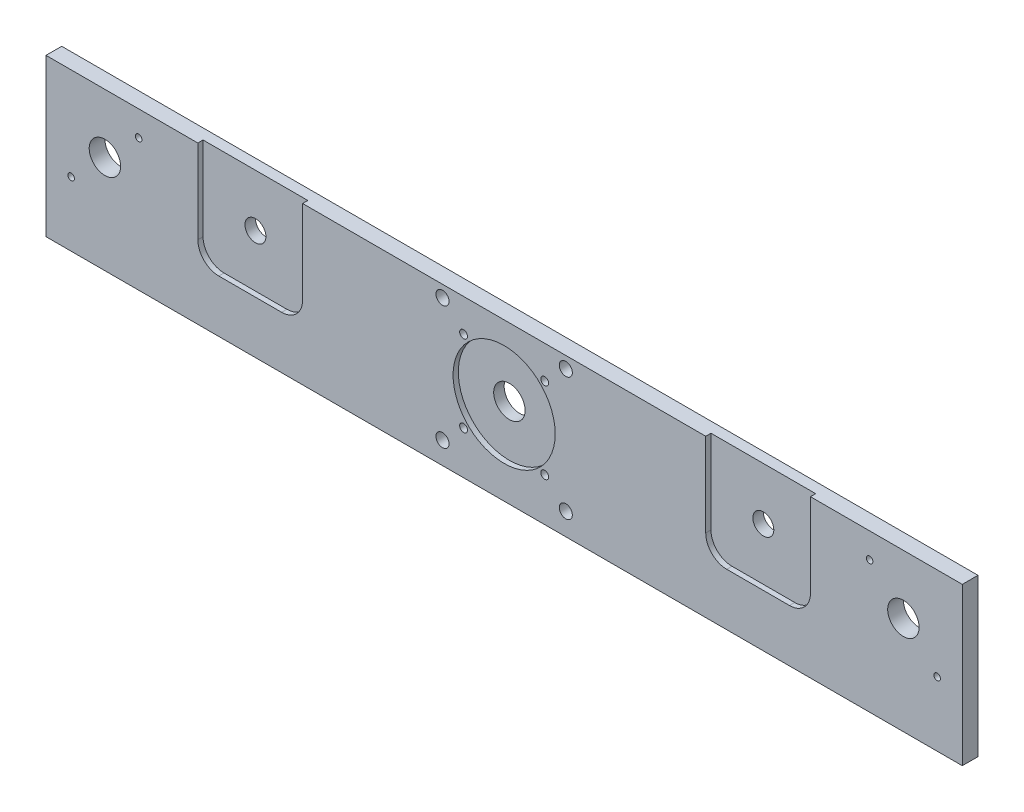
from build123d import *

# Parameters (mm, degrees)
CROQUIS1_W              = 350
CROQUIS1_H              = 60
SALIENTE_EXTRUIR1_DEPTH = 6
CROQUIS2_R              = 6
CROQUIS2_R_2            = 1.25
CORTAR_EXTRUIR1_DEPTH   = 7
CROQUIS3_R              = 6
CROQUIS3_R_2            = 1.5
CROQUIS3_R_3            = 2.5
CORTAR_EXTRUIR2_DEPTH   = 7
CROQUIS5_R              = 19.5
CORTAR_EXTRUIR4_DEPTH   = 2
CROQUIS7_R              = 4
CORTAR_EXTRUIR5_DEPTH   = 5


with BuildPart() as part:
    # Croquis1 → Saliente-Extruir1 (new body)
    with BuildSketch(Plane.XY):
        with Locations((-175, -30)):
            Rectangle(CROQUIS1_W, CROQUIS1_H)
    extrude(amount=SALIENTE_EXTRUIR1_DEPTH)

    # Croquis2 → Cortar-Extruir1 (cut, through all)
    with BuildSketch(Plane.XY.offset(6)):
        with Locations((-327.5, -22.5)):
            Circle(CROQUIS2_R)
        with Locations((-22.5, -22.5)):
            Circle(CROQUIS2_R)
        with Locations((-314.595301243, -9.595301243)):
            Circle(CROQUIS2_R_2)
        with Locations((-340.404698757, -35.404698757)):
            Circle(CROQUIS2_R_2)
        with Locations((-35.404698757, -9.595301243)):
            Circle(CROQUIS2_R_2)
        with Locations((-9.595301243, -35.404698757)):
            Circle(CROQUIS2_R_2)
    extrude(amount=-CORTAR_EXTRUIR1_DEPTH, mode=Mode.SUBTRACT)

    # Croquis3 → Cortar-Extruir2 (cut, through all)
    with BuildSketch(Plane.XY.offset(6)):
        with Locations((-175, -28)):
            Circle(CROQUIS3_R)
        with Locations((-190.5, -12.5)):
            Circle(CROQUIS3_R_2)
        with Locations((-159.5, -12.5)):
            Circle(CROQUIS3_R_2)
        with Locations((-190.5, -43.5)):
            Circle(CROQUIS3_R_2)
        with Locations((-151.45, -51.55)):
            Circle(CROQUIS3_R_3)
        with Locations((-198.55, -51.55)):
            Circle(CROQUIS3_R_3)
        with Locations((-159.5, -43.5)):
            Circle(CROQUIS3_R_2)
        with Locations((-151.45, -4.45)):
            Circle(CROQUIS3_R_3)
        with Locations((-198.55, -4.45)):
            Circle(CROQUIS3_R_3)
    extrude(amount=-CORTAR_EXTRUIR2_DEPTH, mode=Mode.SUBTRACT)

    # Croquis5 → Cortar-Extruir4 (cut)
    with BuildSketch(Plane.XY.offset(6)):
        with Locations((-175, -28)):
            Circle(CROQUIS5_R)
        with BuildLine():
            Line((-292, 0), (-252, 0))
            Line((-252, 0), (-252, -32))
            ThreePointArc((-252, -32), (-254.343145751, -37.656854249), (-260, -40))
            Line((-260, -40), (-284, -40))
            ThreePointArc((-284, -40), (-289.656854249, -37.656854249), (-292, -32))
            Line((-292, -32), (-292, 0))
        make_face()
        with BuildLine():
            Line((-98, 0), (-58, 0))
            Line((-58, 0), (-58, -32))
            ThreePointArc((-58, -32), (-60.343145751, -37.656854249), (-66, -40))
            Line((-66, -40), (-90, -40))
            ThreePointArc((-90, -40), (-95.656854249, -37.656854249), (-98, -32))
            Line((-98, -32), (-98, 0))
        make_face()
    extrude(amount=-CORTAR_EXTRUIR4_DEPTH, mode=Mode.SUBTRACT)

    # Croquis7 → Cortar-Extruir5 (cut, through all)
    with BuildSketch(Plane.XY.offset(4)):
        with Locations((-272, -20)):
            Circle(CROQUIS7_R)
        with Locations((-78, -20)):
            Circle(CROQUIS7_R)
    extrude(amount=-CORTAR_EXTRUIR5_DEPTH, mode=Mode.SUBTRACT)


solid = part.part
